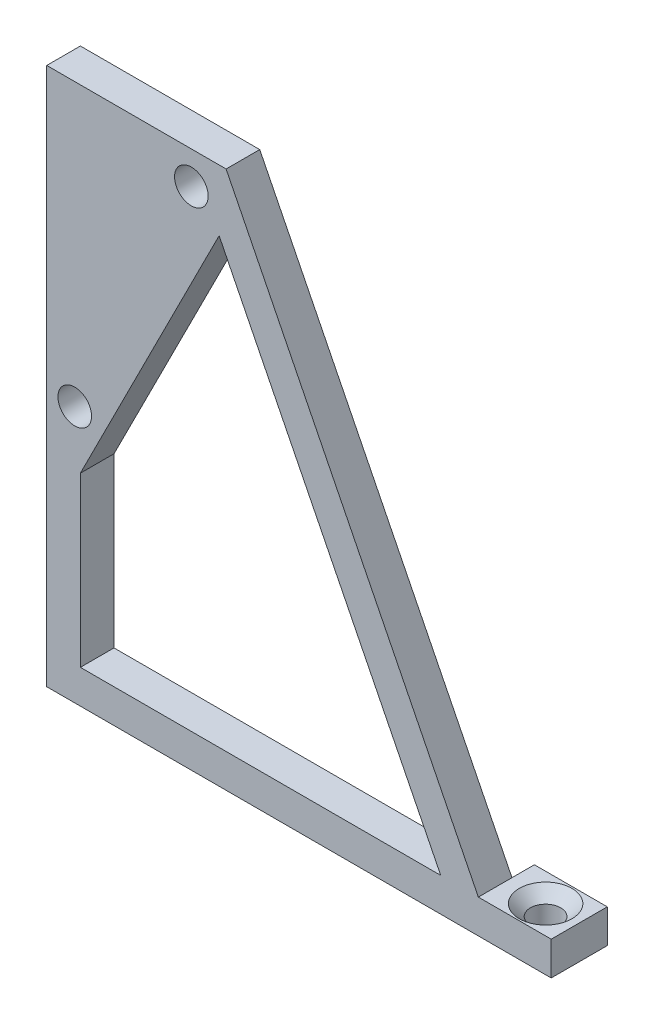
from build123d import *

# Parameters (mm, degrees)
SKICA1_R                 = 1.5
P_IDAT_VYSUNUT_M1_DEPTH  = 3
SKICA3_W                 = 6.5
SKICA3_H                 = 3
P_IDAT_VYSUNUT_M2_DEPTH  = 2
SKICA4_R                 = 1.35
ODEBRAT_VYSUNUT_M1_DEPTH = 3
ZKOSEN_1_SIZE            = 1


with BuildPart() as part:
    # Skica1 → Přidat vysunutím1 (new body)
    with BuildSketch(Plane.XY):
        Polygon((0, 0), (40, 0), (45, 0), (45, 3), (38.5, 3), (16, 48), (0, 48), align=None)
        with Locations((2.5, 22.9)):
            Circle(SKICA1_R, mode=Mode.SUBTRACT)
        with Locations((12.9, 45.1)):
            Circle(SKICA1_R, mode=Mode.SUBTRACT)
        Polygon((3, 3), (35.145898034, 3), (15.37827124, 42.535253588), (3, 18), align=None, mode=Mode.SUBTRACT)
    extrude(amount=P_IDAT_VYSUNUT_M1_DEPTH)

    # Skica3 → Přidat vysunutím2 (add)
    with BuildSketch(Plane(origin=(0, 0, 0), x_dir=(-1, 0, 0), z_dir=(0, 0, -1))):
        with Locations((-41.75, 1.5)):
            Rectangle(SKICA3_W, SKICA3_H)
    extrude(amount=P_IDAT_VYSUNUT_M2_DEPTH)

    # Skica4 → Odebrat vysunutím1 (cut)
    with BuildSketch(Plane(origin=(0, 3, 0), x_dir=(1, 0, 0), z_dir=(0, 1, 0))):
        with Locations((42, -0.5)):
            Circle(SKICA4_R)
    extrude(amount=-ODEBRAT_VYSUNUT_M1_DEPTH, mode=Mode.SUBTRACT)

    # Zkosení1
    zkosen_1_edges = [part.edges().sort_by_distance(p)[0] for p in [
        (40.65, 3, 0.5),
    ]]
    chamfer(zkosen_1_edges, length=ZKOSEN_1_SIZE)


solid = part.part
